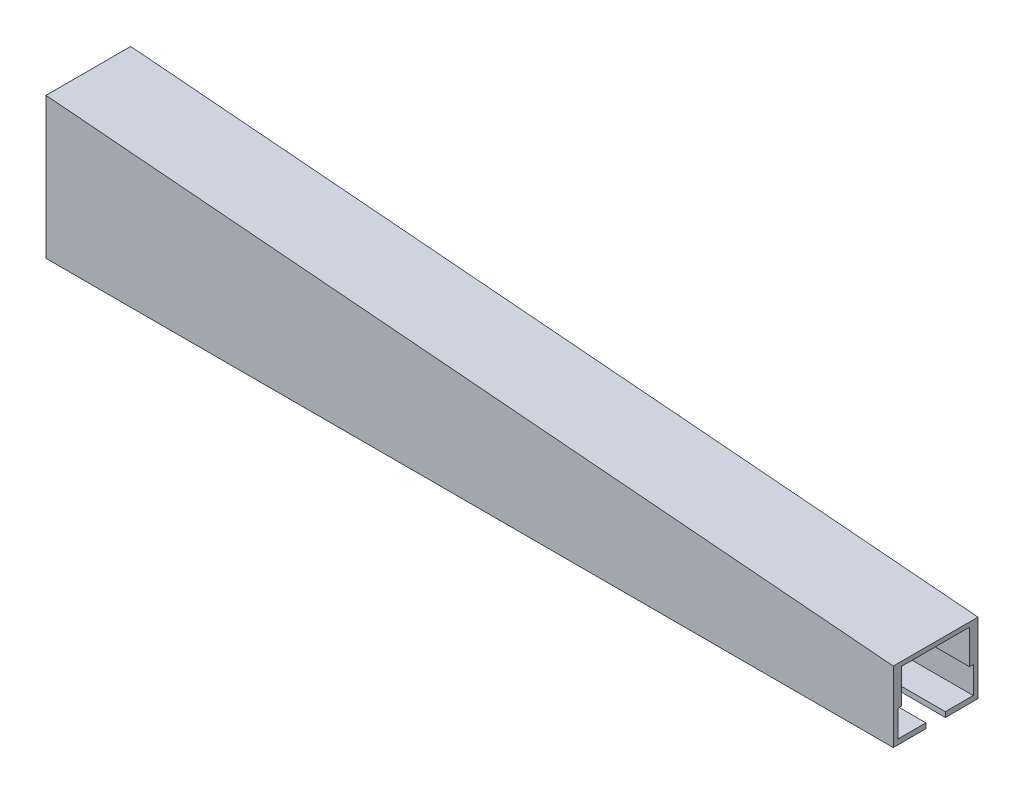
from build123d import *

# Parameters (mm, degrees)
EXTRUDE_1_DEPTH          = 30
CUT_EXTRUDE_1_DEPTH      = 301
CUT_EXTRUDE_2_DEPTH      = 12
CUT_EXTRUDE_2_DEPTH_BACK = 12


with BuildPart() as part:
    # Эскиз1 → Бобышка-Вытянуть1 (new body)
    with BuildSketch(Plane.XY):
        Polygon((0, 0), (300, 0), (300, 25), (0, 50), align=None)
    extrude(amount=EXTRUDE_1_DEPTH)

    # Эскиз2 → Вырез-Вытянуть1 (cut, through all)
    with BuildSketch(Plane(origin=(300, 0, 0), x_dir=(0, 0, -1), z_dir=(1, 0, 0))):
        Polygon((-18.429564861, 0), (-18.429564861, 1.797684404), (-28.323382455, 1.797684404), (-28.323382455, 11.297500412), (-1.676617545, 11.297500412), (-1.676617545, 1.797684404), (-11.570435139, 1.797684404), (-11.570435139, 0), align=None)
    extrude(amount=-CUT_EXTRUDE_1_DEPTH, mode=Mode.SUBTRACT)

    # Эскиз3 → Вырез-Вытянуть2 (cut, two sides)
    with BuildSketch(Plane(origin=(0, 0, 15), x_dir=(-1, 0, 0), z_dir=(0, 0, -1))) as cut_extrude_2_sk:
        Polygon((-300, 7.808397482), (0, 7.808397482), (0, 47.550024082), (-300, 23.437127044), align=None)
    extrude(amount=CUT_EXTRUDE_2_DEPTH, mode=Mode.SUBTRACT)
    extrude(cut_extrude_2_sk.sketch, amount=-CUT_EXTRUDE_2_DEPTH_BACK, mode=Mode.SUBTRACT)


solid = part.part
